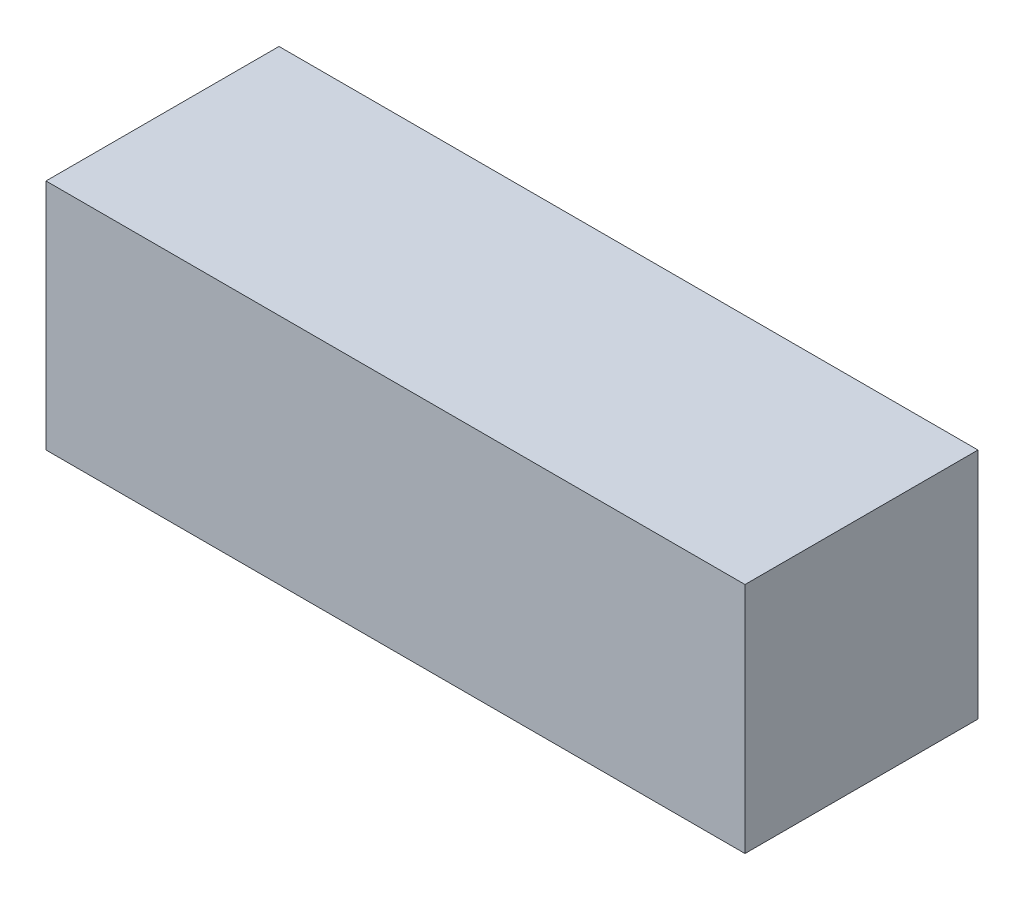
from build123d import *

# Parameters (mm, degrees)
SKETCH_1_W      = 6
SKETCH_1_H      = 2
EXTRUDE_1_DEPTH = 2


with BuildPart() as part:
    # Эскиз1 → Бобышка-Вытянуть1 (new body)
    with BuildSketch(Plane(origin=(0, 0, 0), x_dir=(1, 0, 0), z_dir=(0, 1, 0))):
        Rectangle(SKETCH_1_W, SKETCH_1_H)
    extrude(amount=EXTRUDE_1_DEPTH)


solid = part.part
